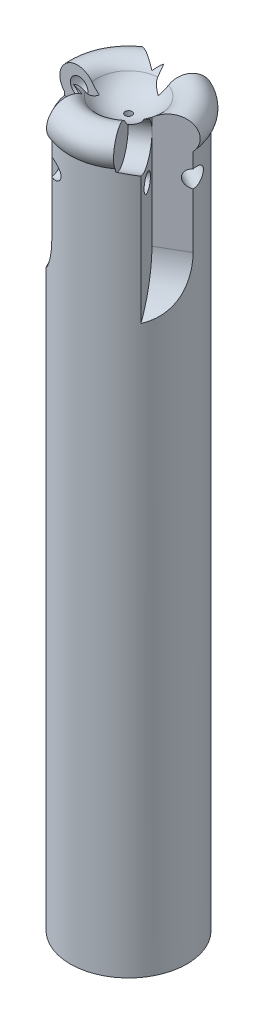
from build123d import *

# Parameters (mm, degrees)
CUT_EXTRUDE_1_DEPTH      = 20
SKETCH_6_R               = 3.5
CUT_EXTRUDE_2_DEPTH      = 3
SKETCH_8_R               = 1.5
CUT_EXTRUDE_3_DEPTH      = 73.105899928
SKETCH_10_R              = 1.5
CUT_EXTRUDE_5_DEPTH      = 2
SKETCH_12_R              = 1.5
CUT_EXTRUDE_6_DEPTH      = 72.549359142
PATTERN_CIRCULAR_1_COUNT = 3


with BuildPart() as part:
    # 草图1 → 旋转1 (revolve)
    with BuildSketch(Plane.XY, mode=Mode.PRIVATE) as revolve_1_sk:
        with BuildLine():
            Line((-10, 64.663941978), (-10, -55.336058022))
            Line((-10, -55.336058022), (0, -55.336058022))
            Line((0, -55.336058022), (0, 65.910364822))
            Line((0, 65.910364822), (-0.327791456, 65.910364822))
            ThreePointArc((-0.327791456, 65.910364822), (-3.168020209, 66.552585472), (-5.371390983, 68.456398478))
            ThreePointArc((-5.371390983, 68.456398478), (-8.730310445, 69.590333031), (-10.825001699, 66.730190364))
            ThreePointArc((-10.825001699, 66.730190364), (-10.611127585, 65.617759446), (-10, 64.663941978))
        make_face()
    revolve(revolve_1_sk.sketch.rotate(Axis((0, 98.0077951, 0), (0, -1, 0)), 270), axis=Axis((0, 98.0077951, 0), (0, -1, 0)))

    # 草图3 → 切除-拉伸1 (cut)
    with BuildSketch(Plane.XY.offset(24)):
        with BuildLine():
            Line((-4, 69.730190364), (-12.714993583, 69.730190364))
            Line((-12.714993583, 69.730190364), (-12.714993583, 41.40567393))
            Line((-12.714993583, 41.40567393), (-10, 41.40567393))
            ThreePointArc((-10, 41.40567393), (-5.657647594, 44.573757244), (-4, 49.686973526))
            Line((-4, 49.686973526), (-4, 69.730190364))
        make_face()
    cut_extrude_1 = extrude(amount=-CUT_EXTRUDE_1_DEPTH, mode=Mode.SUBTRACT)

    # 草图6 → 切除-拉伸2 (cut)
    with BuildSketch(Plane.XY.offset(4)):
        with Locations((-7.46515139, 66.663941978)):
            Circle(SKETCH_6_R)
    cut_extrude_2 = extrude(amount=-CUT_EXTRUDE_2_DEPTH, mode=Mode.SUBTRACT)

    # 草图8 → 切除-拉伸3 (cut, through all)
    with BuildSketch(Plane.XY.offset(4)):
        with Locations((-6.16515139, 60.60453027)):
            Circle(SKETCH_8_R)
    cut_extrude_3 = extrude(amount=-CUT_EXTRUDE_3_DEPTH, mode=Mode.SUBTRACT)

    # 草图10 → 切除-拉伸5 (cut)
    with BuildSketch(Plane(origin=(0, 65.910364822, 0), x_dir=(1, 0, 0), z_dir=(0, 1, 0))):
        with Locations(Location((0, 0, 0), (0, 0, 270))):
            Circle(SKETCH_10_R)
    extrude(amount=-CUT_EXTRUDE_5_DEPTH, mode=Mode.SUBTRACT)

    # 草图12 → 切除-拉伸6 (cut, through all)
    with BuildSketch(Plane.XY.offset(1)):
        with Locations((-7.46515139, 66.663941978)):
            Circle(SKETCH_12_R)
    extrude(amount=-CUT_EXTRUDE_6_DEPTH, mode=Mode.SUBTRACT)

    # 阵列(圆周)1: 切除-拉伸1, 切除-拉伸2, 切除-拉伸3 ×3 about axis
    pattern_circular_1_axis = Axis((0, 0, 0), (0, 1, 0))
    add([cut_extrude_1.rotate(pattern_circular_1_axis, i * 360 / PATTERN_CIRCULAR_1_COUNT) for i in range(1, PATTERN_CIRCULAR_1_COUNT)], mode=Mode.SUBTRACT)
    add([cut_extrude_2.rotate(pattern_circular_1_axis, i * 360 / PATTERN_CIRCULAR_1_COUNT) for i in range(1, PATTERN_CIRCULAR_1_COUNT)], mode=Mode.SUBTRACT)
    add([cut_extrude_3.rotate(pattern_circular_1_axis, i * 360 / PATTERN_CIRCULAR_1_COUNT) for i in range(1, PATTERN_CIRCULAR_1_COUNT)], mode=Mode.SUBTRACT)


solid = part.part
